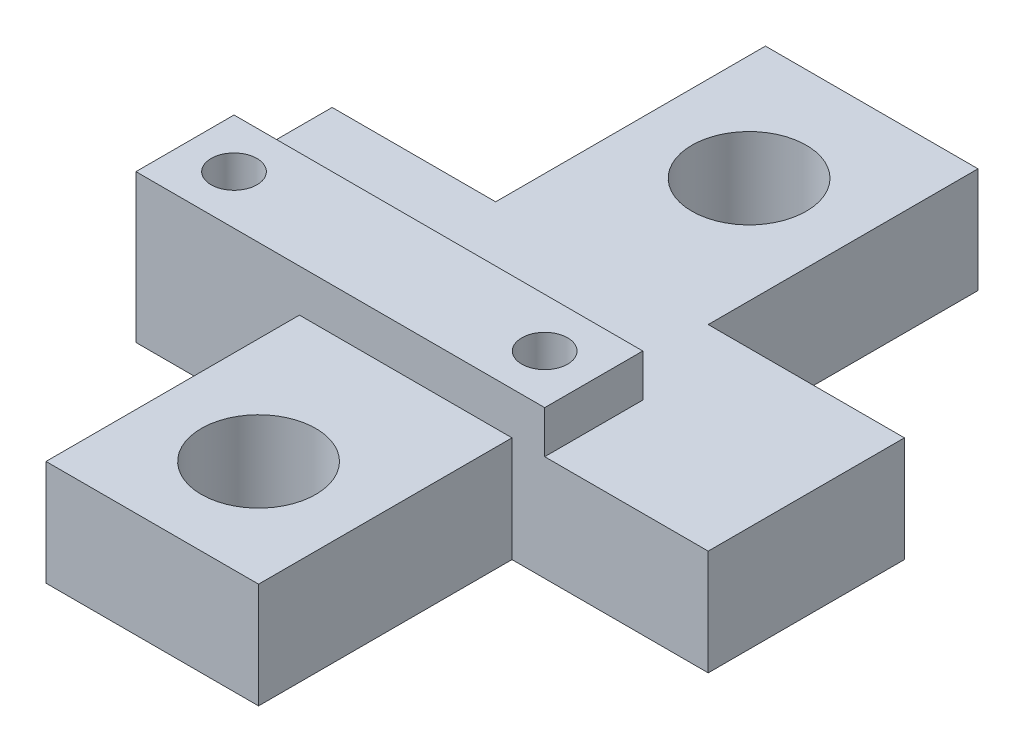
from build123d import *

# Parameters (mm, degrees)
BOSS_EXTRUDE1_DEPTH = 6.45
SKETCH2_W           = 25
SKETCH2_H           = 6
BOSS_EXTRUDE2_DEPTH = 2.6
SKETCH3_R           = 3.5
CUT_EXTRUDE1_DEPTH  = 7.45
SKETCH4_R           = 1.4
CUT_EXTRUDE2_DEPTH  = 10.05


with BuildPart() as part:
    # Sketch1 → Boss-Extrude1 (new body)
    with BuildSketch(Plane(origin=(0, 0, 0), x_dir=(1, 0, 0), z_dir=(0, 1, 0))):
        Polygon((5.5, 6), (5.5, 22.5), (-7.5, 22.5), (-7.5, 6), (-17.5, 6), (-17.5, -6), (-7.5, -6), (-7.5, -21.5), (5.5, -21.5), (5.5, -6), (17.5, -6), (17.5, 6), align=None)
    extrude(amount=BOSS_EXTRUDE1_DEPTH)

    # Sketch2 → Boss-Extrude2 (add)
    with BuildSketch(Plane(origin=(0, 6.45, 0), x_dir=(1, 0, 0), z_dir=(0, 1, 0))):
        with Locations((-5, -3)):
            Rectangle(SKETCH2_W, SKETCH2_H)
    extrude(amount=BOSS_EXTRUDE2_DEPTH)

    # Sketch3 → Cut-Extrude1 (cut, through all)
    with BuildSketch(Plane(origin=(0, 6.45, 0), x_dir=(1, 0, 0), z_dir=(0, 1, 0))):
        with Locations((-1, 15)):
            Circle(SKETCH3_R)
        with Locations((-1, -15)):
            Circle(SKETCH3_R)
    extrude(amount=-CUT_EXTRUDE1_DEPTH, mode=Mode.SUBTRACT)

    # Sketch4 → Cut-Extrude2 (cut, through all)
    with BuildSketch(Plane(origin=(0, 9.05, 0), x_dir=(1, 0, 0), z_dir=(0, 1, 0))):
        with Locations((-14.5, -3)):
            Circle(SKETCH4_R)
        with Locations((4.5, -3)):
            Circle(SKETCH4_R)
    extrude(amount=-CUT_EXTRUDE2_DEPTH, mode=Mode.SUBTRACT)


solid = part.part
